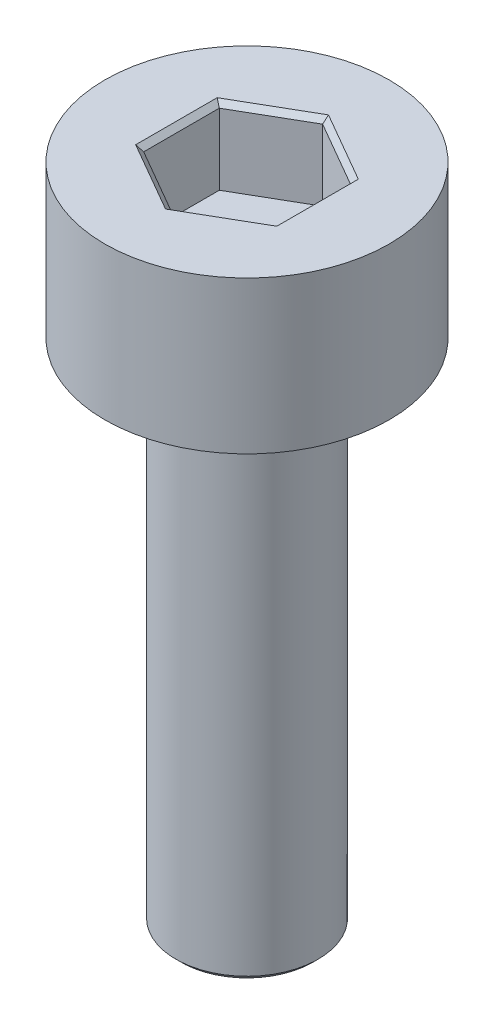
from build123d import *

# Parameters (mm, degrees)
SKETCH_1_R          = 2.8
EXTRUDE_1_DEPTH     = 3
CUT_EXTRUDE_1_DEPTH = 1.5
SKETCH_3_R          = 1.4
EXTRUDE_2_DEPTH     = 10
CHAMFER_1_SIZE      = 0.1


with BuildPart() as part:
    # 草图1 → 凸台-拉伸1 (new body)
    with BuildSketch(Plane(origin=(0, 0, 0), x_dir=(1, 0, 0), z_dir=(0, 1, 0))):
        Circle(SKETCH_1_R)
    extrude(amount=EXTRUDE_1_DEPTH)

    # 草图2 → 切除-拉伸1 (cut)
    with BuildSketch(Plane(origin=(0, 3, 0), x_dir=(1, 0, 0), z_dir=(0, 1, 0))):
        Polygon((0, -1.489563695), (1.29, -0.744781847), (1.29, 0.744781847), (0, 1.489563695), (-1.29, 0.744781847), (-1.29, -0.744781847), align=None)
    extrude(amount=-CUT_EXTRUDE_1_DEPTH, mode=Mode.SUBTRACT)

    # 草图3 → 凸台-拉伸2 (add)
    with BuildSketch(Plane.XZ):
        Circle(SKETCH_3_R)
    extrude(amount=EXTRUDE_2_DEPTH)

    # 倒角1
    chamfer_1_edges = [part.edges().sort_by_distance(p)[0] for p in [
        (-0.645, 3, 1.117172771),
        (0.645, 3, 1.117172771),
        (1.29, 3, 0),
        (0.645, 3, -1.117172771),
        (-0.645, 3, -1.117172771),
        (-1.29, 3, 0),
        (-1.4, -10, 0),
    ]]
    chamfer(chamfer_1_edges, length=CHAMFER_1_SIZE)


solid = part.part
